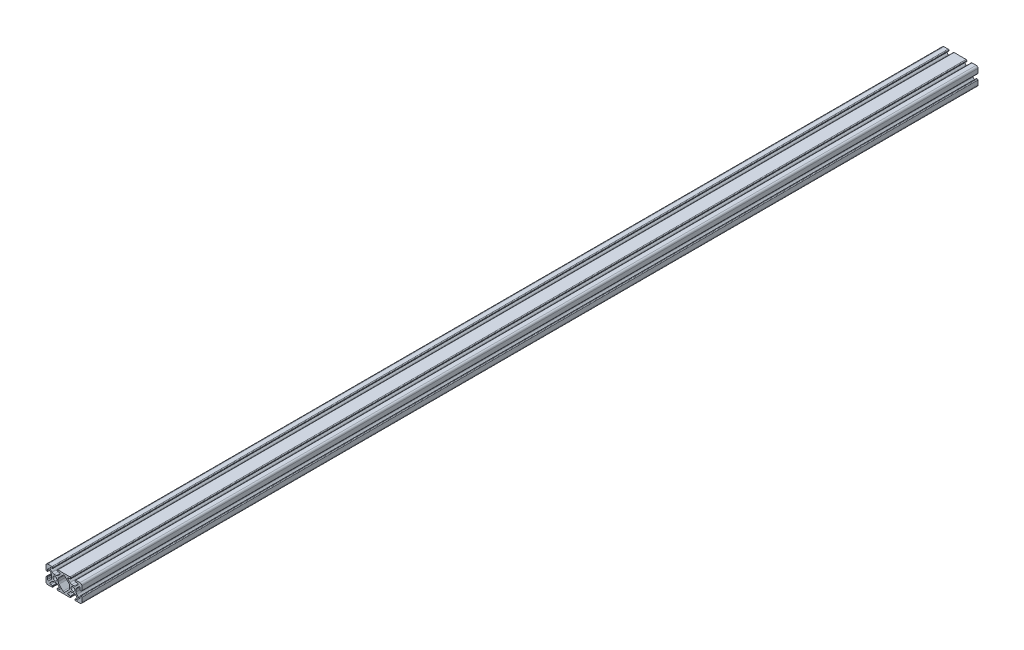
from build123d import *

# Parameters (mm, degrees)
SKETCH1_R           = 2.1463
BOSS_EXTRUDE1_DEPTH = 500


with BuildPart() as part:
    # Sketch1 → Boss-Extrude1 (new body, symmetric)
    with BuildSketch(Plane.XY):
        with BuildLine():
            Line((-19.9898, 7.9883), (-19.9898, 3.2893))
            ThreePointArc((-19.9898, 3.2893), (-19.75917588, 2.73252412), (-19.2024, 2.5019))
            Line((-19.2024, 2.5019), (-18.4912, 2.5019))
            ThreePointArc((-18.4912, 2.5019), (-18.275673853, 2.591173853), (-18.1864, 2.8067))
            Line((-18.1864, 2.8067), (-18.1864, 4.9149))
            ThreePointArc((-18.1864, 4.9149), (-17.668965253, 5.689295824), (-16.755503096, 5.507596904))
            Line((-16.755503096, 5.507596904), (-14.500665747, 3.252759555))
            ThreePointArc((-14.500665747, 3.252759555), (-13.850954457, 2.280397894), (-13.622806192, 1.133419111))
            Line((-13.622806192, 1.133419111), (-13.622806192, -1.133419111))
            ThreePointArc((-13.622806192, -1.133419111), (-13.850954457, -2.280397894), (-14.500665747, -3.252759555))
            Line((-14.500665747, -3.252759555), (-16.755503096, -5.507596904))
            ThreePointArc((-16.755503096, -5.507596904), (-17.668965253, -5.689295824), (-18.1864, -4.9149))
            Line((-18.1864, -4.9149), (-18.1864, -2.8067))
            ThreePointArc((-18.1864, -2.8067), (-18.275673853, -2.591173853), (-18.4912, -2.5019))
            Line((-18.4912, -2.5019), (-19.2024, -2.5019))
            ThreePointArc((-19.2024, -2.5019), (-19.75917588, -2.73252412), (-19.9898, -3.2893))
            Line((-19.9898, -3.2893), (-19.9898, -7.9883))
            ThreePointArc((-19.9898, -7.9883), (-19.402080467, -9.407180467), (-17.9832, -9.9949))
            Line((-17.9832, -9.9949), (-13.2842, -9.9949))
            ThreePointArc((-13.2842, -9.9949), (-12.72742412, -9.76427588), (-12.4968, -9.2075))
            Line((-12.4968, -9.2075), (-12.4968, -8.4963))
            ThreePointArc((-12.4968, -8.4963), (-12.586073853, -8.280773853), (-12.8016, -8.1915))
            Line((-12.8016, -8.1915), (-14.9098, -8.1915))
            ThreePointArc((-14.9098, -8.1915), (-15.684195824, -7.674065253), (-15.502496904, -6.760603096))
            Line((-15.502496904, -6.760603096), (-13.247659555, -4.505765747))
            ThreePointArc((-13.247659555, -4.505765747), (-12.275297894, -3.856054457), (-11.128319111, -3.627906192))
            Line((-11.128319111, -3.627906192), (-8.861480889, -3.627906192))
            ThreePointArc((-8.861480889, -3.627906192), (-7.714502106, -3.856054457), (-6.742140445, -4.505765747))
            Line((-6.742140445, -4.505765747), (-4.487303096, -6.760603096))
            ThreePointArc((-4.487303096, -6.760603096), (-4.305604176, -7.674065253), (-5.08, -8.1915))
            Line((-5.08, -8.1915), (-7.1882, -8.1915))
            ThreePointArc((-7.1882, -8.1915), (-7.403726147, -8.280773853), (-7.493, -8.4963))
            Line((-7.493, -8.4963), (-7.493, -9.2075))
            ThreePointArc((-7.493, -9.2075), (-7.26237588, -9.76427588), (-6.7056, -9.9949))
            Line((-6.7056, -9.9949), (0, -9.9949))
            Line((0, -9.9949), (6.7056, -9.9949))
            ThreePointArc((6.7056, -9.9949), (7.26237588, -9.76427588), (7.493, -9.2075))
            Line((7.493, -9.2075), (7.493, -8.4963))
            ThreePointArc((7.493, -8.4963), (7.403726147, -8.280773853), (7.1882, -8.1915))
            Line((7.1882, -8.1915), (5.08, -8.1915))
            ThreePointArc((5.08, -8.1915), (4.305604176, -7.674065253), (4.487303096, -6.760603096))
            Line((4.487303096, -6.760603096), (6.742140445, -4.505765747))
            ThreePointArc((6.742140445, -4.505765747), (7.714502106, -3.856054457), (8.861480889, -3.627906192))
            Line((8.861480889, -3.627906192), (11.128319111, -3.627906192))
            ThreePointArc((11.128319111, -3.627906192), (12.275297894, -3.856054457), (13.247659555, -4.505765747))
            Line((13.247659555, -4.505765747), (15.502496904, -6.760603096))
            ThreePointArc((15.502496904, -6.760603096), (15.684195824, -7.674065253), (14.9098, -8.1915))
            Line((14.9098, -8.1915), (12.8016, -8.1915))
            ThreePointArc((12.8016, -8.1915), (12.586073853, -8.280773853), (12.4968, -8.4963))
            Line((12.4968, -8.4963), (12.4968, -9.2075))
            ThreePointArc((12.4968, -9.2075), (12.72742412, -9.76427588), (13.2842, -9.9949))
            Line((13.2842, -9.9949), (17.9832, -9.9949))
            ThreePointArc((17.9832, -9.9949), (19.402080467, -9.407180467), (19.9898, -7.9883))
            Line((19.9898, -7.9883), (19.9898, -3.2893))
            ThreePointArc((19.9898, -3.2893), (19.75917588, -2.73252412), (19.2024, -2.5019))
            Line((19.2024, -2.5019), (18.4912, -2.5019))
            ThreePointArc((18.4912, -2.5019), (18.275673853, -2.591173853), (18.1864, -2.8067))
            Line((18.1864, -2.8067), (18.1864, -4.9149))
            ThreePointArc((18.1864, -4.9149), (17.668965253, -5.689295824), (16.755503096, -5.507596904))
            Line((16.755503096, -5.507596904), (14.500665747, -3.252759555))
            ThreePointArc((14.500665747, -3.252759555), (13.850954457, -2.280397894), (13.622806192, -1.133419111))
            Line((13.622806192, -1.133419111), (13.622806192, 1.133419111))
            ThreePointArc((13.622806192, 1.133419111), (13.850954457, 2.280397894), (14.500665747, 3.252759555))
            Line((14.500665747, 3.252759555), (16.755503096, 5.507596904))
            ThreePointArc((16.755503096, 5.507596904), (17.668965253, 5.689295824), (18.1864, 4.9149))
            Line((18.1864, 4.9149), (18.1864, 2.8067))
            ThreePointArc((18.1864, 2.8067), (18.275673853, 2.591173853), (18.4912, 2.5019))
            Line((18.4912, 2.5019), (19.2024, 2.5019))
            ThreePointArc((19.2024, 2.5019), (19.75917588, 2.73252412), (19.9898, 3.2893))
            Line((19.9898, 3.2893), (19.9898, 7.9883))
            ThreePointArc((19.9898, 7.9883), (19.402080467, 9.407180467), (17.9832, 9.9949))
            Line((17.9832, 9.9949), (13.2842, 9.9949))
            ThreePointArc((13.2842, 9.9949), (12.72742412, 9.76427588), (12.4968, 9.2075))
            Line((12.4968, 9.2075), (12.4968, 8.4963))
            ThreePointArc((12.4968, 8.4963), (12.586073853, 8.280773853), (12.8016, 8.1915))
            Line((12.8016, 8.1915), (14.9098, 8.1915))
            ThreePointArc((14.9098, 8.1915), (15.684195824, 7.674065253), (15.502496904, 6.760603096))
            Line((15.502496904, 6.760603096), (13.247659555, 4.505765747))
            ThreePointArc((13.247659555, 4.505765747), (12.275297894, 3.856054457), (11.128319111, 3.627906192))
            Line((11.128319111, 3.627906192), (8.861480889, 3.627906192))
            ThreePointArc((8.861480889, 3.627906192), (7.714502106, 3.856054457), (6.742140445, 4.505765747))
            Line((6.742140445, 4.505765747), (4.487303096, 6.760603096))
            ThreePointArc((4.487303096, 6.760603096), (4.305604176, 7.674065253), (5.08, 8.1915))
            Line((5.08, 8.1915), (7.1882, 8.1915))
            ThreePointArc((7.1882, 8.1915), (7.403726147, 8.280773853), (7.493, 8.4963))
            Line((7.493, 8.4963), (7.493, 9.2075))
            ThreePointArc((7.493, 9.2075), (7.26237588, 9.76427588), (6.7056, 9.9949))
            Line((6.7056, 9.9949), (0, 9.9949))
            Line((0, 9.9949), (-6.7056, 9.9949))
            ThreePointArc((-6.7056, 9.9949), (-7.26237588, 9.76427588), (-7.493, 9.2075))
            Line((-7.493, 9.2075), (-7.493, 8.4963))
            ThreePointArc((-7.493, 8.4963), (-7.403726147, 8.280773853), (-7.1882, 8.1915))
            Line((-7.1882, 8.1915), (-5.08, 8.1915))
            ThreePointArc((-5.08, 8.1915), (-4.305604176, 7.674065253), (-4.487303096, 6.760603096))
            Line((-4.487303096, 6.760603096), (-6.742140445, 4.505765747))
            ThreePointArc((-6.742140445, 4.505765747), (-7.714502106, 3.856054457), (-8.861480889, 3.627906192))
            Line((-8.861480889, 3.627906192), (-11.128319111, 3.627906192))
            ThreePointArc((-11.128319111, 3.627906192), (-12.275297894, 3.856054457), (-13.247659555, 4.505765747))
            Line((-13.247659555, 4.505765747), (-15.502496904, 6.760603096))
            ThreePointArc((-15.502496904, 6.760603096), (-15.684195824, 7.674065253), (-14.9098, 8.1915))
            Line((-14.9098, 8.1915), (-12.8016, 8.1915))
            ThreePointArc((-12.8016, 8.1915), (-12.586073853, 8.280773853), (-12.4968, 8.4963))
            Line((-12.4968, 8.4963), (-12.4968, 9.2075))
            ThreePointArc((-12.4968, 9.2075), (-12.72742412, 9.76427588), (-13.2842, 9.9949))
            Line((-13.2842, 9.9949), (-17.9832, 9.9949))
            ThreePointArc((-17.9832, 9.9949), (-19.402080467, 9.407180467), (-19.9898, 7.9883))
        make_face()
        with Locations((-9.9949, 0)):
            Circle(SKETCH1_R, mode=Mode.SUBTRACT)
        with Locations((9.9949, 0)):
            Circle(SKETCH1_R, mode=Mode.SUBTRACT)
        with BuildLine():
            Line((-6.366993808, 1.133419111), (-6.366993808, -1.133419111))
            ThreePointArc((-6.366993808, -1.133419111), (-6.138845543, -2.280397894), (-5.489134253, -3.252759555))
            Line((-5.489134253, -3.252759555), (-0.939581002, -7.802312806))
            ThreePointArc((-0.939581002, -7.802312806), (0, -8.1915), (0.939581002, -7.802312806))
            Line((0.939581002, -7.802312806), (5.489134253, -3.252759555))
            ThreePointArc((5.489134253, -3.252759555), (6.138845543, -2.280397894), (6.366993808, -1.133419111))
            Line((6.366993808, -1.133419111), (6.366993808, 1.133419111))
            ThreePointArc((6.366993808, 1.133419111), (6.138845543, 2.280397894), (5.489134253, 3.252759555))
            Line((5.489134253, 3.252759555), (0.939581002, 7.802312806))
            ThreePointArc((0.939581002, 7.802312806), (0, 8.1915), (-0.939581002, 7.802312806))
            Line((-0.939581002, 7.802312806), (-5.489134253, 3.252759555))
            ThreePointArc((-5.489134253, 3.252759555), (-6.138845543, 2.280397894), (-6.366993808, 1.133419111))
        make_face(mode=Mode.SUBTRACT)
    extrude(amount=BOSS_EXTRUDE1_DEPTH, both=True)


solid = part.part
